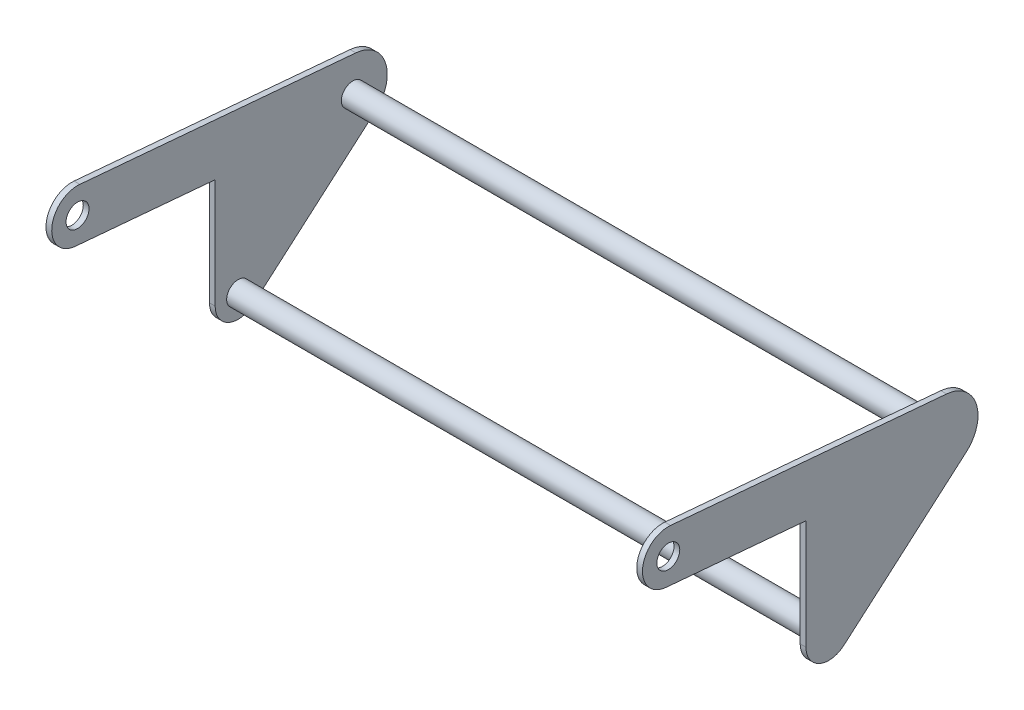
from build123d import *

# Parameters (mm, degrees)
BOSS_EXTRUDE1_DEPTH     = 660.4
SKETCH2_W               = 647.7
SKETCH2_H               = 371.475
CUT_EXTRUDE1_DEPTH      = 192.802928595
CUT_EXTRUDE1_DEPTH_BACK = 26.4
BOSS_EXTRUDE2_REACH     = 662.4
SKETCH3_R               = 12.7
SKETCH4_R               = 12.7
CUT_EXTRUDE2_DEPTH      = 1
CUT_EXTRUDE2_DEPTH_BACK = 661.4


with BuildPart() as part:
    # Sketch1 → Boss-Extrude1 (new body)
    with BuildSketch(Plane(origin=(0, 0, 0), x_dir=(0, 0, -1), z_dir=(1, 0, 0))):
        with BuildLine():
            Line((-180.290475349, 134.761665097), (-25.4, 121.210504416))
            Line((-25.4, 121.210504416), (-25.4, 0))
            ThreePointArc((-25.4, 0), (-10.544261728, -23.107975779), (16.645554694, -19.185554694))
            Line((16.645554694, -19.185554694), (151.968332041, 98.221667959))
            ThreePointArc((151.968332041, 98.221667959), (163.240880217, 138.756215424), (130.320633799, 164.955017997))
            Line((130.320633799, 164.955017997), (-175.309524651, 191.694192093))
            ThreePointArc((-175.309524651, 191.694192093), (-206.266263498, 165.718403944), (-180.290475349, 134.761665097))
        make_face()
    extrude(amount=BOSS_EXTRUDE1_DEPTH)

    # Sketch2 → Cut-Extrude1 (cut, two sides)
    with BuildSketch(Plane(origin=(0, 0, 0), x_dir=(1, 0, 0), z_dir=(0, 1, 0))) as cut_extrude1_sk:
        with Locations((330.2, -20.6375)):
            Rectangle(SKETCH2_W, SKETCH2_H)
    extrude(amount=CUT_EXTRUDE1_DEPTH, mode=Mode.SUBTRACT)
    extrude(cut_extrude1_sk.sketch, amount=-CUT_EXTRUDE1_DEPTH_BACK, mode=Mode.SUBTRACT)

    # Sketch3 → Boss-Extrude2 (add, up to next)
    with BuildSketch(Plane(origin=(660.4, 0, 0), x_dir=(0, 0, -1), z_dir=(1, 0, 0)), mode=Mode.PRIVATE) as boss_extrude2_sk1:
        with Locations((127, 127)):
            Circle(SKETCH3_R)
    boss_extrude2_tool1 = extrude(boss_extrude2_sk1.sketch, amount=-BOSS_EXTRUDE2_REACH, mode=Mode.PRIVATE) - part.part
    add(boss_extrude2_tool1.solids().sort_by_distance((660.4, 127, -127))[0])
    # Sketch3 → Boss-Extrude2 (add, up to next)
    with BuildSketch(Plane(origin=(660.4, 0, 0), x_dir=(0, 0, -1), z_dir=(1, 0, 0)), mode=Mode.PRIVATE) as boss_extrude2_sk2:
        Circle(SKETCH3_R)
    boss_extrude2_tool2 = extrude(boss_extrude2_sk2.sketch, amount=-BOSS_EXTRUDE2_REACH, mode=Mode.PRIVATE) - part.part
    add(boss_extrude2_tool2.solids().sort_by_distance((660.4, 0, 0))[0])

    # Sketch4 → Cut-Extrude2 (cut, two sides)
    with BuildSketch(Plane(origin=(660.4, 0, 0), x_dir=(0, 0, -1), z_dir=(1, 0, 0))) as cut_extrude2_sk:
        with Locations((-177.8, 163.227928595)):
            Circle(SKETCH4_R)
    extrude(amount=CUT_EXTRUDE2_DEPTH, mode=Mode.SUBTRACT)
    extrude(cut_extrude2_sk.sketch, amount=-CUT_EXTRUDE2_DEPTH_BACK, mode=Mode.SUBTRACT)


solid = part.part
